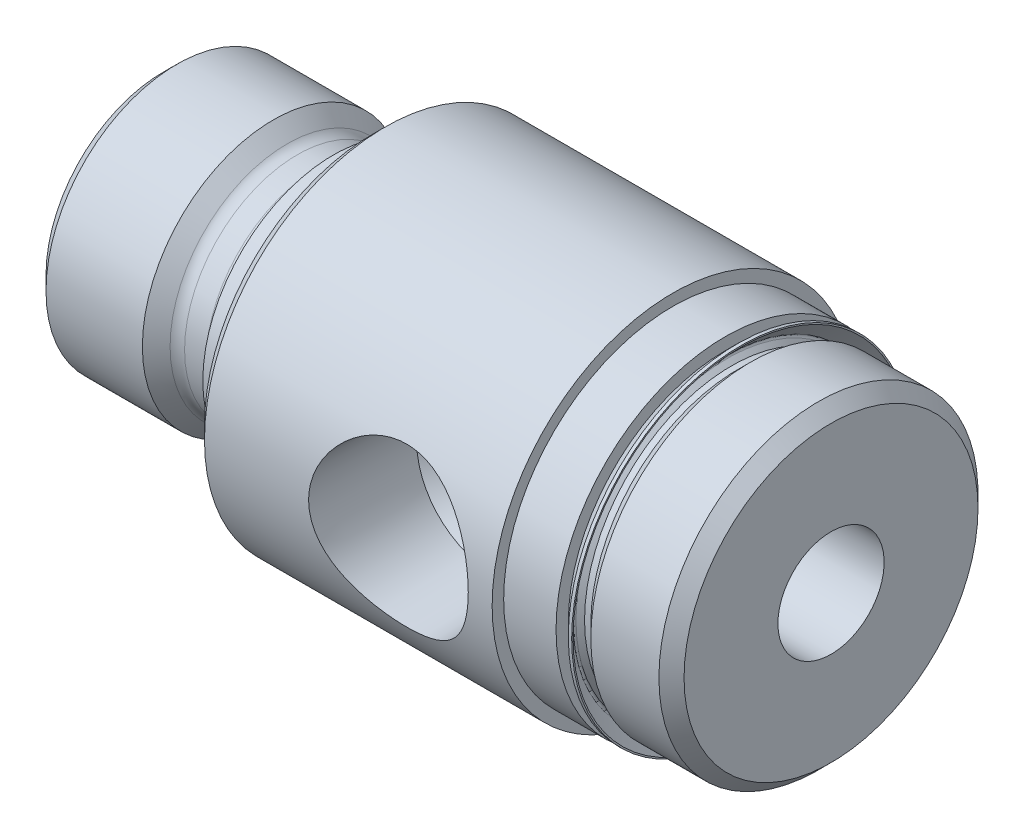
from build123d import *

# Parameters (mm, degrees)
HOLE1_D           = 6.4389
HOLE1_CSINK_D     = 6.9469
HOLE1_CSINK_ANGLE = 90
SKETCH5_W         = 3.175
SKETCH5_H         = 5.08


with BuildPart() as part:
    # Sketch1 → Revolve1 (revolve)
    with BuildSketch(Plane.XY):
        with BuildLine():
            Line((0, 0), (0, 7.09803))
            Line((0, 7.09803), (0.83947, 7.9375))
            Line((0.83947, 7.9375), (6.681592328, 7.9375))
            Line((6.681592328, 7.9375), (7.520171502, 7.096504435))
            ThreePointArc((7.520171502, 7.096504435), (7.804772216, 6.905895804), (8.1407, 6.83895))
            Line((8.1407, 6.83895), (9.4361, 6.83895))
            ThreePointArc((9.4361, 6.83895), (10.055737672, 7.095612328), (10.3124, 7.71525))
            Line((10.3124, 7.71525), (10.3124, 7.90575))
            Line((10.3124, 7.90575), (12.7, 7.90575))
            Line((12.7, 7.90575), (12.7, 0))
            Line((12.7, 0), (0, 0))
        make_face()
    revolve(axis=Axis((12.7, 0, 0), (-1, 0, 0)))

    # Sketch2 → Revolve2 (revolve)
    with BuildSketch(Plane.XY):
        Polygon((12.7, 0), (12.7, 10.19175), (13.462, 10.95375), (34.0741, 10.95375), (34.0741, 8.90905), (34.8361, 8.90905), (35.5981, 9.67105), (39.7256, 9.67105), (40.4876, 8.90905), (40.4876, 0), align=None)
    revolve(axis=Axis((40.4876, 0, 0), (-1, 0, 0)))

    # Hole1 (through all)
    with Locations(Plane.ZY):
        with Locations((0, 0)):
            CounterSinkHole(HOLE1_D / 2, HOLE1_CSINK_D / 2, counter_sink_angle=HOLE1_CSINK_ANGLE)

    # Sketch5 → Cut-Revolve1 (revolve, cut)
    with BuildSketch(Plane.XY):
        with Locations((32.4866, 12.79525)):
            Rectangle(SKETCH5_W, SKETCH5_H)
    revolve(axis=Axis((34.0741, 0, 0), (-1, 0, 0)), mode=Mode.SUBTRACT)

    # Sketch6 → Cut-Revolve2 (revolve, cut)
    with BuildSketch(Plane(origin=(0, 0, 0), x_dir=(1, 0, 0), z_dir=(0, 1, 0))):
        Polygon((24.6126, 0), (27.7876, 0), (27.7876, -3.137518166), (29.253831834, -4.60375), (29.452075925, -10.95375), (24.6126, -10.95375), align=None)
    revolve(axis=Axis((24.6126, 0, 10.95375), (0, 0, -1)), mode=Mode.SUBTRACT)

    # Sketch7 → Revolve3 (revolve)
    with BuildSketch(Plane.XY):
        with BuildLine():
            Line((34.0741, 8.65505), (34.8361, 8.65505))
            Line((34.8361, 8.65505), (34.8361, 8.90905))
            Line((34.8361, 8.90905), (34.4551, 8.90905))
            Line((34.4551, 8.90905), (34.196587194, 9.167562806))
            ThreePointArc((34.196587194, 9.167562806), (34.159389755, 9.257365367), (34.196587194, 9.347167928))
            Line((34.196587194, 9.347167928), (35.02050107, 10.171081804))
            Line((35.02050107, 10.171081804), (35.02050107, 10.25525))
            Line((35.02050107, 10.25525), (34.81730107, 10.25525))
            Line((34.81730107, 10.25525), (34.0741, 9.51204893))
            Line((34.0741, 9.51204893), (34.0741, 8.65505))
        make_face()
    revolve(axis=Axis((34.8361, 0, 0), (-1, 0, 0)))


solid = part.part
